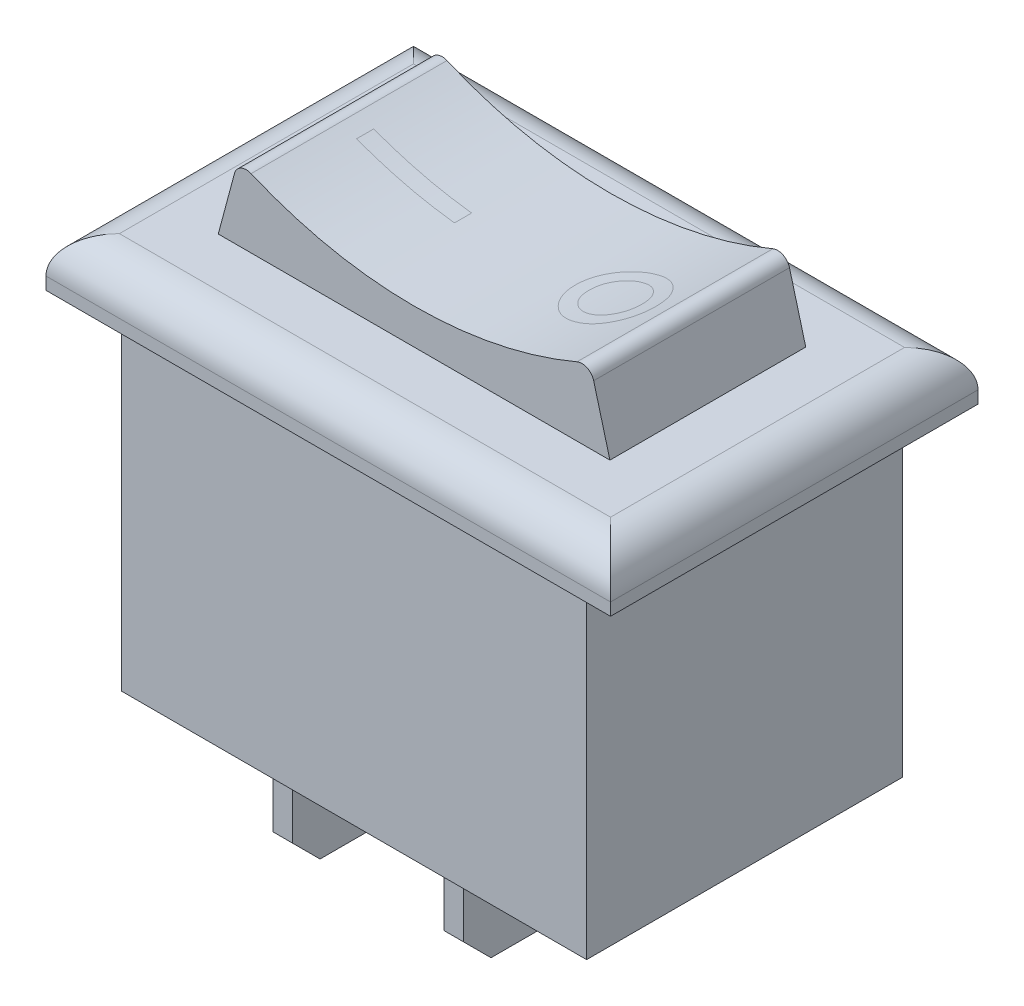
from build123d import *

# Parameters (mm, degrees)
BODY_DEPTH          = 7.5057
SKETCH2_W           = 1.0541
SKETCH2_H           = 13.6906
NARROW_DEPTH        = 24.0632
PANEL_FILLET_R      = 1.5
SKETCH4_W           = 0.7874
SKETCH4_H           = 7.0866
TERMINALS_DEPTH     = 12.9032
TERMINALS_2_DEPTH   = 12.9032
SKETCH5_OUTSIDE_W   = 24.158
SKETCH5_OUTSIDE_H   = 31.93
TERMINAL_TRIM_DEPTH = 22.0312
TOGGLE_DEPTH        = 4
TOGGLE_DEPTH_BACK   = 4


with BuildPart() as part:
    # Sketch1 → body (new body, symmetric)
    with BuildSketch(Plane.XY):
        Polygon((-11.5316, 0), (-9.4996, 0), (-9.4996, -13.6906), (9.4996, -13.6906), (9.4996, 0), (11.5316, 0), (11.5316, 2.0066), (-11.5316, 2.0066), align=None)
    extrude(amount=BODY_DEPTH, both=True)

    # Sketch2 → narrow (cut, through all)
    with BuildSketch(Plane(origin=(11.5316, 0, 0), x_dir=(0, 0, -1), z_dir=(1, 0, 0))):
        with Locations((-6.97865, -6.8453)):
            Rectangle(SKETCH2_W, SKETCH2_H)
        with Locations((6.97865, -6.8453)):
            Rectangle(SKETCH2_W, SKETCH2_H)
    extrude(amount=-NARROW_DEPTH, mode=Mode.SUBTRACT)

    # panel_fillet
    panel_fillet_edges = [part.edges().sort_by_distance(p)[0] for p in [
        (-11.5316, 2.0066, 0),
        (11.5316, 2.0066, 0),
        (0, 2.0066, 7.5057),
        (0, 2.0066, -7.5057),
    ]]
    fillet(panel_fillet_edges, radius=PANEL_FILLET_R)

    # Sketch6 → toggle (add, two sides)
    with BuildSketch(Plane.XY) as toggle_sk:
        with BuildLine():
            Line((-7.336295271, 4.48357977), (-8, 2.0066))
            Line((-8, 2.0066), (8, 2.0066))
            Line((8, 2.0066), (7.336295271, 4.48357977))
            ThreePointArc((7.336295271, 4.48357977), (7.072301131, 4.803672947), (6.657522862, 4.814233984))
            ThreePointArc((6.657522862, 4.814233984), (0, 3.456401012), (-6.657522862, 4.814233984))
            ThreePointArc((-6.657522862, 4.814233984), (-7.072301131, 4.803672947), (-7.336295271, 4.48357977))
        make_face()
    extrude(amount=TOGGLE_DEPTH)
    extrude(toggle_sk.sketch, amount=-TOGGLE_DEPTH_BACK)


with BuildPart() as body_2:
    # Sketch4 → terminals (new body)
    with BuildSketch(Plane.XY.offset(6.4516)):
        with Locations((-6.985, -17.2339)):
            Rectangle(SKETCH4_W, SKETCH4_H)
    extrude(amount=-TERMINALS_DEPTH)


with BuildPart() as body_3:
    # Sketch4 → terminals 2 (new body)
    with BuildSketch(Plane.XY.offset(6.4516)):
        with Locations((0, -17.2339)):
            Rectangle(SKETCH4_W, SKETCH4_H)
    extrude(amount=-TERMINALS_2_DEPTH)


with BuildPart() as terminal_trim_tool:
    # Sketch5 outside → terminal_trim (new body, through all)
    with BuildSketch(Plane.ZY.offset(9.4996)):
        with Locations((0, -9.385)):
            Rectangle(SKETCH5_OUTSIDE_W, SKETCH5_OUTSIDE_H)
        Polygon((-2.3749, -19.6523), (-1.25, -20.7772), (1.25, -20.7772), (2.3749, -19.6523), (2.3749, -13.6906), (-2.3749, -13.6906), align=None, mode=Mode.SUBTRACT)
        with BuildLine():
            Line((-1.082531755, -17.1522), (-0.649519053, -17.9022))
            ThreePointArc((-0.649519053, -17.9022), (0, -18.2772), (0.649519053, -17.9022))
            Line((0.649519053, -17.9022), (1.082531755, -17.1522))
            ThreePointArc((1.082531755, -17.1522), (0, -15.2772), (-1.082531755, -17.1522))
        make_face()
    extrude(amount=-TERMINAL_TRIM_DEPTH)


with BuildPart() as body_3_1:
    add(body_3.part)

    # terminal_trim: cut by terminal_trim_tool
    add(terminal_trim_tool.part, mode=Mode.SUBTRACT)


with BuildPart() as body_2_1:
    add(body_2.part)

    # terminal_trim: cut by terminal_trim_tool
    add(terminal_trim_tool.part, mode=Mode.SUBTRACT)


solid = Compound([part.part, body_3_1.part, body_2_1.part])
